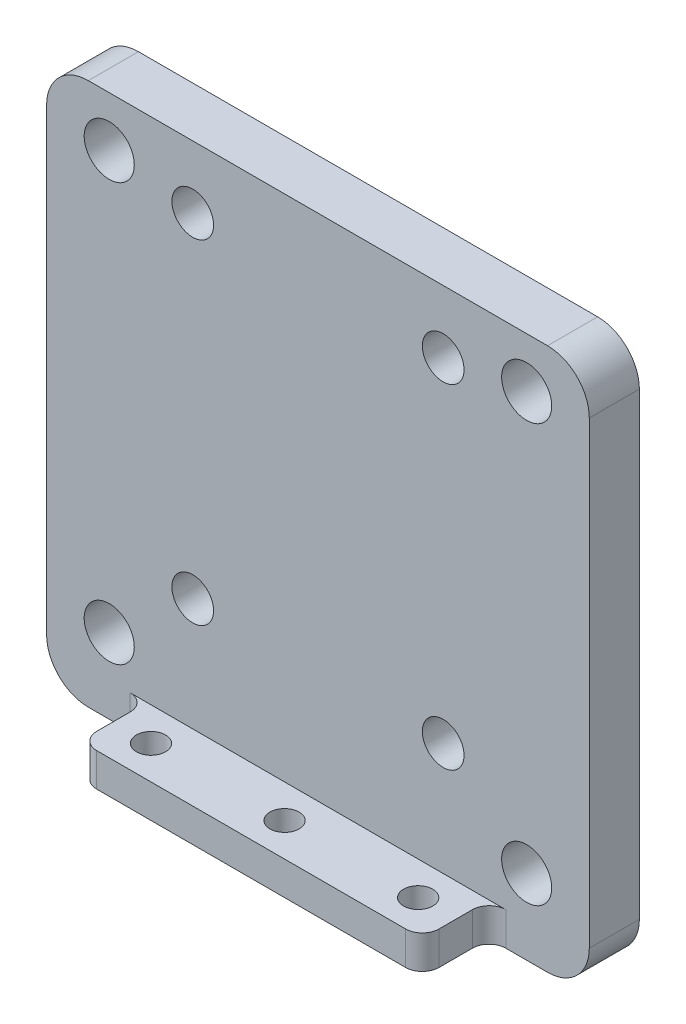
from build123d import *

# Parameters (mm, degrees)
SKETCH1_W           = 65
SKETCH1_H           = 65
SKETCH1_R           = 3
BOSS_EXTRUDE1_DEPTH = 6
FILLET1_R           = 5
SKETCH2_W           = 41
SKETCH2_H           = 4
BOSS_EXTRUDE2_DEPTH = 8
FILLET2_R           = 2
SKETCH3_R           = 2.5
CUT_EXTRUDE1_DEPTH  = 15
SKETCH_1_R          = 1.75
CUT_EXTRUDE_1_DEPTH = 66


with BuildPart() as part:
    # Sketch1 → Boss-Extrude1 (new body)
    with BuildSketch(Plane.XY):
        Rectangle(SKETCH1_W, SKETCH1_H)
        with Locations((25, 26.5)):
            Circle(SKETCH1_R, mode=Mode.SUBTRACT)
        with Locations((25, -23.5)):
            Circle(SKETCH1_R, mode=Mode.SUBTRACT)
        with Locations((-25, -23.5)):
            Circle(SKETCH1_R, mode=Mode.SUBTRACT)
        with Locations((-25, 26.5)):
            Circle(SKETCH1_R, mode=Mode.SUBTRACT)
    extrude(amount=BOSS_EXTRUDE1_DEPTH)

    # Fillet1
    fillet1_edges = [part.edges().sort_by_distance(p)[0] for p in [
        (32.5, -32.5, 3),
        (-32.5, -32.5, 3),
        (-32.5, 32.5, 3),
        (32.5, 32.5, 3),
    ]]
    fillet(fillet1_edges, radius=FILLET1_R)

    # Sketch2 → Boss-Extrude2 (add)
    with BuildSketch(Plane.XY.offset(6)):
        with Locations((0, -30.5)):
            Rectangle(SKETCH2_W, SKETCH2_H)
    extrude(amount=BOSS_EXTRUDE2_DEPTH)

    # Fillet2
    fillet2_edges = [part.edges().sort_by_distance(p)[0] for p in [
        (-20.5, -30.5, 6),
        (20.5, -30.5, 6),
        (-20.5, -30.5, 14),
        (20.5, -30.5, 14),
    ]]
    fillet(fillet2_edges, radius=FILLET2_R)

    # Sketch3 → Cut-Extrude1 (cut, through all)
    with BuildSketch(Plane(origin=(0, 0, 0), x_dir=(-1, 0, 0), z_dir=(0, 0, -1))):
        with Locations((-15, 25)):
            Circle(SKETCH3_R)
        with Locations((15, 25)):
            Circle(SKETCH3_R)
        with Locations((-15, -15)):
            Circle(SKETCH3_R)
        with Locations((15, -15)):
            Circle(SKETCH3_R)
    extrude(amount=-CUT_EXTRUDE1_DEPTH, mode=Mode.SUBTRACT)

    # 草图1 → 切除-拉伸1 (cut, through all)
    with BuildSketch(Plane.XZ.offset(32.5)):
        with Locations((-16, 10)):
            Circle(SKETCH_1_R)
        with Locations((0, 10)):
            Circle(SKETCH_1_R)
        with Locations((16, 10)):
            Circle(SKETCH_1_R)
    extrude(amount=-CUT_EXTRUDE_1_DEPTH, mode=Mode.SUBTRACT)


solid = part.part
